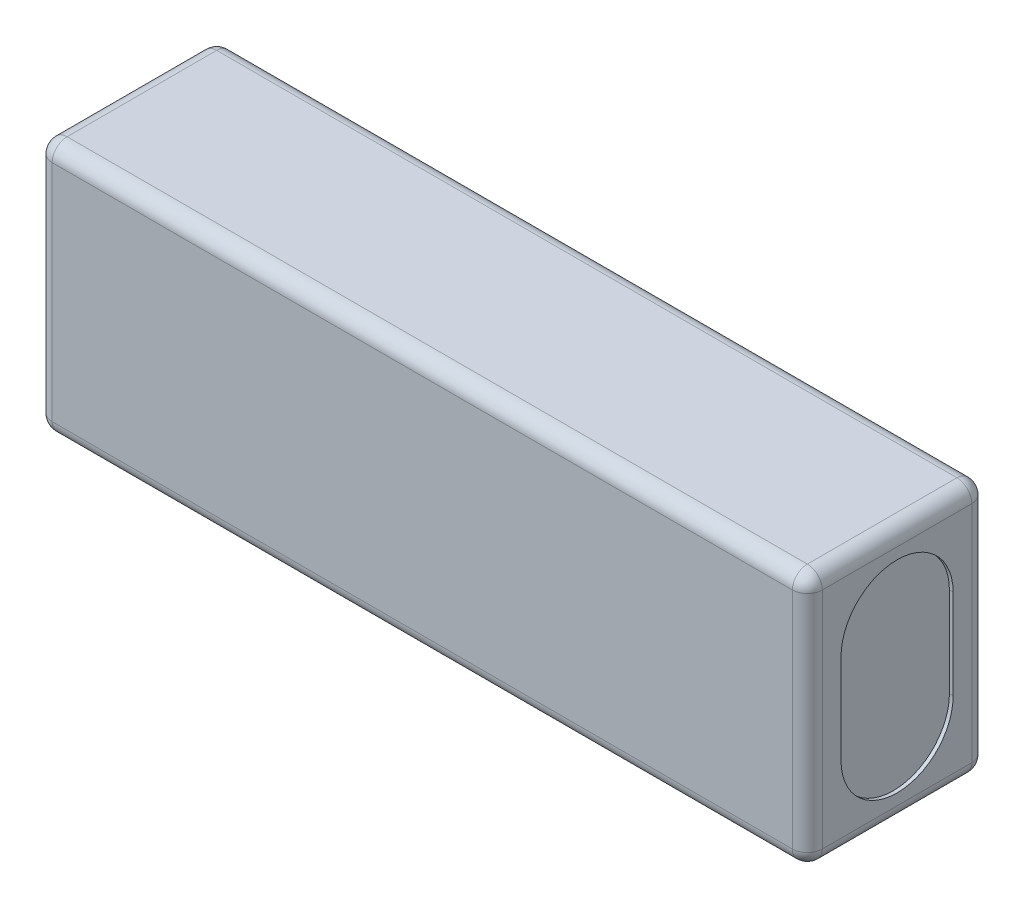
from build123d import *

# Parameters (mm, degrees)
ESBO_O1_W                = 103
ESBO_O1_H                = 34
RESSALTO_EXTRUS_O1_DEPTH = 24
CORTE_EXTRUS_O1_DEPTH    = 0.5
FILETE1_R                = 2


with BuildPart() as part:
    # Esboço1 → Ressalto-extrusão1 (new body)
    with BuildSketch(Plane.XY):
        Rectangle(ESBO_O1_W, ESBO_O1_H)
    extrude(amount=RESSALTO_EXTRUS_O1_DEPTH)

    # Esboço2 → Corte-extrusão1 (cut)
    with BuildSketch(Plane(origin=(51.5, 0, 0), x_dir=(0, 0, -1), z_dir=(1, 0, 0))):
        with BuildLine():
            Line((-4.5, 6), (-4.5, -6))
            ThreePointArc((-4.5, -6), (-12, -13.5), (-19.5, -6))
            Line((-19.5, -6), (-19.5, 6))
            ThreePointArc((-19.5, 6), (-12, 13.5), (-4.5, 6))
        make_face()
    corte_extrus_o1 = extrude(amount=-CORTE_EXTRUS_O1_DEPTH, mode=Mode.SUBTRACT)

    # Espelhar1: Corte-extrusão1 across plane
    add(corte_extrus_o1.mirror(Plane(origin=(0, 0, 0), x_dir=(0, 0, 1), z_dir=(1, 0, 0))), mode=Mode.SUBTRACT)

    # Filete1
    filete1_edges = [part.edges().sort_by_distance(p)[0] for p in [
        (-51.5, 0, 24),
        (0, -17, 24),
        (51.5, 0, 24),
        (0, -17, 0),
        (-51.5, 0, 0),
        (0, 17, 0),
        (51.5, 0, 0),
        (0, 17, 24),
        (51.5, -17, 12),
        (-51.5, -17, 12),
        (-51.5, 17, 12),
        (51.5, 17, 12),
    ]]
    fillet(filete1_edges, radius=FILETE1_R)


solid = part.part
